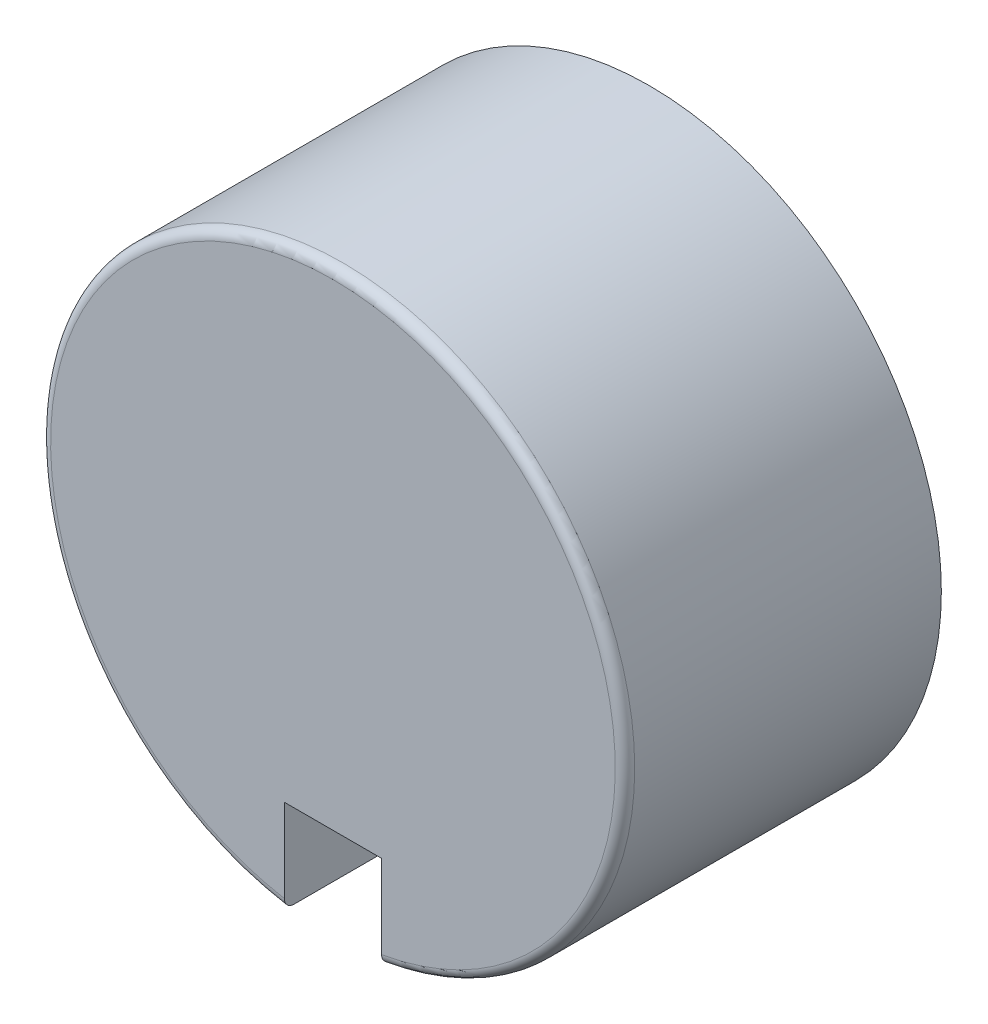
from build123d import *

# Parameters (mm, degrees)
SKETCH_1_R          = 6
SKETCH_1_R_2        = 4.9
EXTRUDE_1_DEPTH     = 6.5
SKETCH_1_2_R        = 4.9
EXTRUDE_2_DEPTH     = 1
FILLET_2_R          = 0.2
SKETCH_8_W          = 2
SKETCH_8_H          = 2
CUT_EXTRUDE_2_DEPTH = 2


with BuildPart() as part:
    # Sketch 1 → Extrude 1 (new body)
    with BuildSketch(Plane.XY):
        Circle(SKETCH_1_R)
        Circle(SKETCH_1_R_2, mode=Mode.SUBTRACT)
    extrude(amount=-EXTRUDE_1_DEPTH)

    # Sketch 1_2 → Extrude 2 (add)
    with BuildSketch(Plane.XY):
        Circle(SKETCH_1_2_R)
    extrude(amount=-EXTRUDE_2_DEPTH)

    # Fillet 2
    fillet_2_edges = [part.edges().sort_by_distance(p)[0] for p in [
        (-6, 0, 0),
    ]]
    fillet(fillet_2_edges, radius=FILLET_2_R)

    # Sketch 8 → Cut-Extrude 2 (cut)
    with BuildSketch(Plane(origin=(0, -6, 0), x_dir=(1, 0, 0), z_dir=(0, 1, 0))):
        with Locations((0, 1)):
            Rectangle(SKETCH_8_W, SKETCH_8_H)
    extrude(amount=CUT_EXTRUDE_2_DEPTH, mode=Mode.SUBTRACT)


solid = part.part
